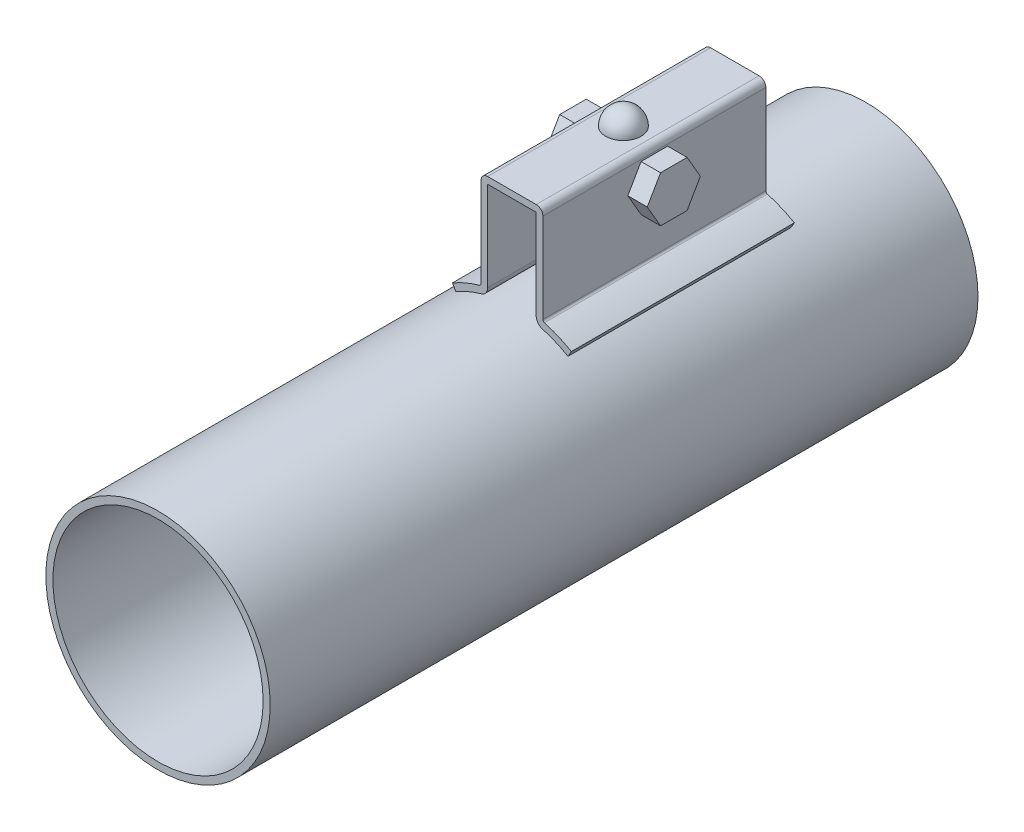
from build123d import *

# Parameters (mm, degrees)
SKETCH1_R                = 31.7
SKETCH1_R_2              = 29.7
BOSS_EXTRUDE1_DEPTH      = 200
BOSS_EXTRUDE2_DEPTH      = 63
BOSS_EXTRUDE3_DEPTH      = 5.5
BOSS_EXTRUDE3_DEPTH_BACK = 23


with BuildPart() as part:
    # Sketch1 → Boss-Extrude1 (new body)
    with BuildSketch(Plane.XY):
        Circle(SKETCH1_R)
        Circle(SKETCH1_R_2, mode=Mode.SUBTRACT)
    extrude(amount=BOSS_EXTRUDE1_DEPTH)

    # Sketch4 → Boss-Extrude2 (add)
    with BuildSketch(Plane(origin=(0, 0, 100), x_dir=(-1, 0, 0), z_dir=(0, 0, -1))):
        with BuildLine():
            Line((-6.85, 32.897074338), (-6.85, 58.2))
            Line((-6.85, 58.2), (6.85, 58.2))
            Line((6.85, 58.2), (6.85, 32.897074338))
            ThreePointArc((6.85, 32.897074338), (7.355169327, 31.390206532), (8.666520468, 30.492317442))
            ThreePointArc((8.666520468, 30.492317442), (12.352096929, 29.194446415), (15.85, 27.4530053))
            Line((15.85, 27.4530053), (16.8, 29.098453567))
            ThreePointArc((16.8, 29.098453567), (13.092443432, 30.944271279), (9.185964912, 32.319932683))
            ThreePointArc((9.185964912, 32.319932683), (8.871240638, 32.535426065), (8.75, 32.897074338))
            Line((8.75, 32.897074338), (8.75, 58.2))
            ThreePointArc((8.75, 58.2), (8.193502884, 59.543502884), (6.85, 60.1))
            Line((6.85, 60.1), (-6.85, 60.1))
            ThreePointArc((-6.85, 60.1), (-8.193502884, 59.543502884), (-8.75, 58.2))
            Line((-8.75, 58.2), (-8.75, 32.897074338))
            ThreePointArc((-8.75, 32.897074338), (-8.871240638, 32.535426065), (-9.185964912, 32.319932683))
            ThreePointArc((-9.185964912, 32.319932683), (-13.092443432, 30.944271279), (-16.8, 29.098453567))
            Line((-16.8, 29.098453567), (-15.85, 27.4530053))
            ThreePointArc((-15.85, 27.4530053), (-12.352096929, 29.194446415), (-8.666520468, 30.492317442))
            ThreePointArc((-8.666520468, 30.492317442), (-7.355169327, 31.390206532), (-6.85, 32.897074338))
        make_face()
    extrude(amount=BOSS_EXTRUDE2_DEPTH)

    # Sketch5 one side → Revolve1 (revolve)
    with BuildSketch(Plane.ZY):
        with BuildLine():
            Line((68.5, 60.1), (68.5, 65.1))
            ThreePointArc((68.5, 65.1), (64.964466094, 63.635533906), (63.5, 60.1))
            Line((63.5, 60.1), (68.5, 60.1))
        make_face()
    revolve(axis=Axis((0, 60.1, 68.5), (0, 1, 0)))

    # Sketch6 → Boss-Extrude3 (add, two sides)
    with BuildSketch(Plane.ZY.offset(8.75)) as boss_extrude3_sk:
        Polygon((72.25277675, 44.7), (76.005553499, 51.2), (72.25277675, 57.7), (64.74722325, 57.7), (60.994446501, 51.2), (64.74722325, 44.7), align=None)
    extrude(amount=BOSS_EXTRUDE3_DEPTH)
    extrude(boss_extrude3_sk.sketch, amount=-BOSS_EXTRUDE3_DEPTH_BACK)


solid = part.part
